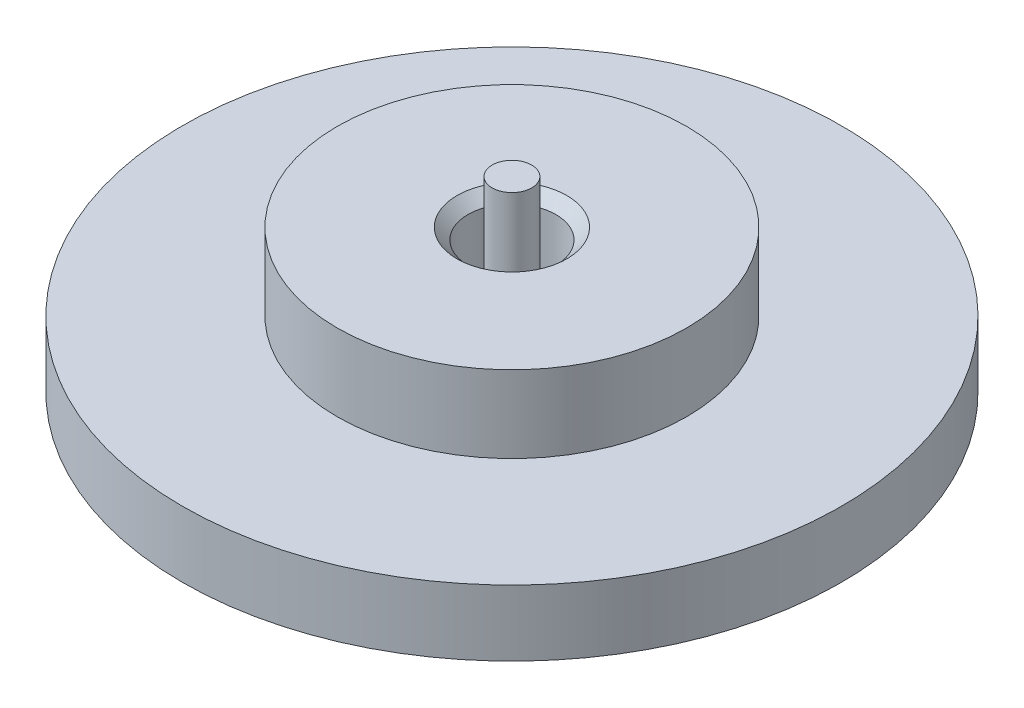
from build123d import *

# Parameters (mm, degrees)
SKETCH_1_R          = 15
EXTRUDE_1_DEPTH     = 3
SKETCH_2_R          = 7.95
EXTRUDE_2_DEPTH     = 3.5
SKETCH_3_R          = 0.9
EXTRUDE_3_DEPTH     = 2
SKETCH_4_R          = 2
SKETCH_4_R_2        = 0.9
CUT_EXTRUDE_1_DEPTH = 3
CHAMFER_1_SIZE      = 0.5


with BuildPart() as part:
    # 草图1 → 凸台-拉伸1 (new body)
    with BuildSketch(Plane(origin=(0, 0, 0), x_dir=(1, 0, 0), z_dir=(0, 1, 0))):
        Circle(SKETCH_1_R)
    extrude(amount=EXTRUDE_1_DEPTH)

    # 草图2 → 凸台-拉伸2 (add)
    with BuildSketch(Plane(origin=(0, 3, 0), x_dir=(1, 0, 0), z_dir=(0, 1, 0))):
        Circle(SKETCH_2_R)
    extrude(amount=EXTRUDE_2_DEPTH)

    # 草图3 → 凸台-拉伸3 (add)
    with BuildSketch(Plane(origin=(0, 6.5, 0), x_dir=(1, 0, 0), z_dir=(0, 1, 0))):
        Circle(SKETCH_3_R)
    extrude(amount=EXTRUDE_3_DEPTH)

    # 草图4 → 切除-拉伸1 (cut)
    with BuildSketch(Plane(origin=(0, 6.5, 0), x_dir=(1, 0, 0), z_dir=(0, 1, 0))):
        Circle(SKETCH_4_R)
        Circle(SKETCH_4_R_2, mode=Mode.SUBTRACT)
    extrude(amount=-CUT_EXTRUDE_1_DEPTH, mode=Mode.SUBTRACT)

    # 倒角1
    chamfer_1_edges = [part.edges().sort_by_distance(p)[0] for p in [
        (-2, 6.5, 0),
    ]]
    chamfer(chamfer_1_edges, length=CHAMFER_1_SIZE)


solid = part.part
